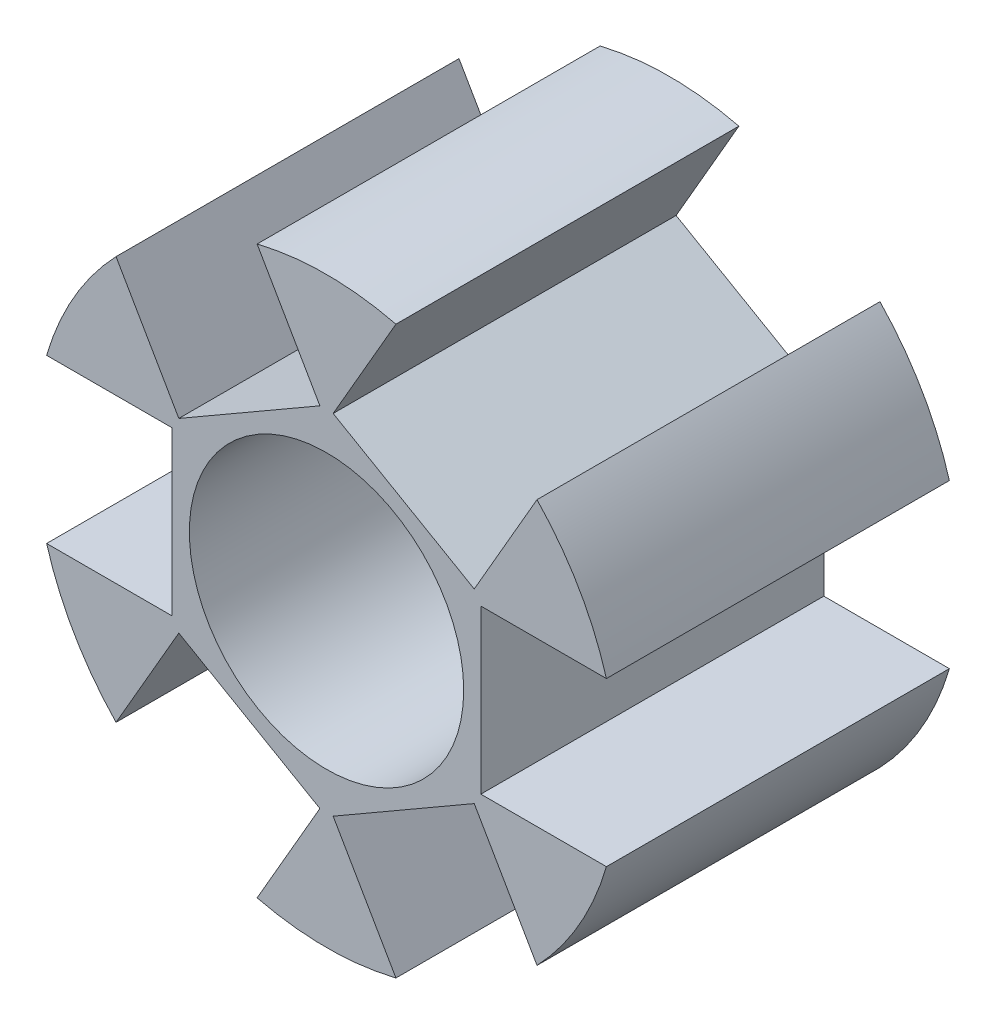
from build123d import *

# Parameters (mm, degrees)
SKETCH1_R           = 8.5
SKETCH1_R_2         = 4
BOSS_EXTRUDE1_DEPTH = 5
SKETCH2_W           = 4.75
SKETCH2_H           = 10
CUT_EXTRUDE3_DEPTH  = 4
CIRPATTERN1_COUNT   = 6


with BuildPart() as part:
    # Sketch1 → Boss-Extrude1 (new, symmetric)
    with BuildSketch(Plane.XY):
        Circle(SKETCH1_R)
        Circle(SKETCH1_R_2, mode=Mode.SUBTRACT)
    extrude(amount=BOSS_EXTRUDE1_DEPTH, both=True)

    # Sketch2 → Cut-Extrude3 (cut)
    with BuildSketch(Plane(origin=(-8.5, -17.193061184, 0), x_dir=(0, -1, 0), z_dir=(1, 0, 0))):
        with Locations((-17.193061184, 0)):
            Rectangle(SKETCH2_W, SKETCH2_H)
    cut_extrude3 = extrude(amount=CUT_EXTRUDE3_DEPTH, mode=Mode.SUBTRACT)

    # CirPattern1: Cut-Extrude3 ×6 about axis
    cirpattern1_axis = Axis((0, 0, 5), (0, 0, 1))
    for i in range(1, CIRPATTERN1_COUNT):
        add(cut_extrude3.rotate(cirpattern1_axis, i * 360 / CIRPATTERN1_COUNT), mode=Mode.SUBTRACT)


solid = part.part
